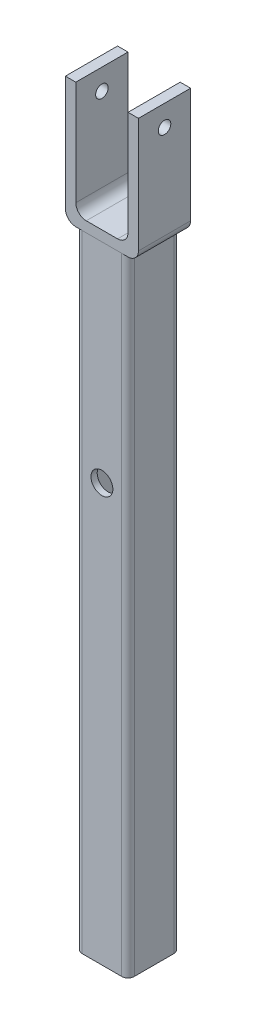
from build123d import *

# Parameters (mm, degrees)
BOSS_EXTRUDE1_DEPTH = 300
SKETCH2_R           = 7.5
CUT_EXTRUDE1_DEPTH  = 3
SKETCH3_R           = 5.25
CUT_EXTRUDE2_DEPTH  = 3
SKETCH5_W           = 35
SKETCH5_H           = 25
BOSS_EXTRUDE2_DEPTH = 60
SKETCH7_W           = 25
SKETCH7_H           = 25
CUT_EXTRUDE4_DEPTH  = 55
SKETCH8_R           = 3
CUT_EXTRUDE5_DEPTH  = 55
FILLET1_R           = 5
FILLET2_R           = 5


with BuildPart() as part:
    # Sketch1 → Boss-Extrude1 (new body)
    with BuildSketch(Plane(origin=(0, 0, 0), x_dir=(1, 0, 0), z_dir=(0, 1, 0))):
        with BuildLine():
            Line((9.5, 12.5), (-9.5, 12.5))
            ThreePointArc((-9.5, 12.5), (-11.621320344, 11.621320344), (-12.5, 9.5))
            Line((-12.5, 9.5), (-12.5, -9.5))
            ThreePointArc((-12.5, -9.5), (-11.621320344, -11.621320344), (-9.5, -12.5))
            Line((-9.5, -12.5), (9.5, -12.5))
            ThreePointArc((9.5, -12.5), (11.621320344, -11.621320344), (12.5, -9.5))
            Line((12.5, -9.5), (12.5, 9.5))
            ThreePointArc((12.5, 9.5), (11.621320344, 11.621320344), (9.5, 12.5))
        make_face()
        with BuildLine():
            Line((-6.5, 9.5), (6.5, 9.5))
            ThreePointArc((6.5, 9.5), (8.621320344, 8.621320344), (9.5, 6.5))
            Line((9.5, 6.5), (9.5, -6.5))
            ThreePointArc((9.5, -6.5), (8.621320344, -8.621320344), (6.5, -9.5))
            Line((6.5, -9.5), (-6.5, -9.5))
            ThreePointArc((-6.5, -9.5), (-8.621320344, -8.621320344), (-9.5, -6.5))
            Line((-9.5, -6.5), (-9.5, 6.5))
            ThreePointArc((-9.5, 6.5), (-8.621320344, 8.621320344), (-6.5, 9.5))
        make_face(mode=Mode.SUBTRACT)
    extrude(amount=BOSS_EXTRUDE1_DEPTH)

    # Sketch2 → Cut-Extrude1 (cut)
    with BuildSketch(Plane(origin=(0, 0, -12.5), x_dir=(-1, 0, 0), z_dir=(0, 0, -1))):
        with Locations((0, 200)):
            Circle(SKETCH2_R)
    extrude(amount=-CUT_EXTRUDE1_DEPTH, mode=Mode.SUBTRACT)

    # Sketch3 → Cut-Extrude2 (cut)
    with BuildSketch(Plane.XY.offset(12.5)):
        with Locations((0, 200)):
            Circle(SKETCH3_R)
    extrude(amount=-CUT_EXTRUDE2_DEPTH, mode=Mode.SUBTRACT)


with BuildPart() as body_2:
    # Sketch5 → Boss-Extrude2 (new body)
    with BuildSketch(Plane(origin=(0, 300, 0), x_dir=(1, 0, 0), z_dir=(0, 1, 0))):
        Rectangle(SKETCH5_W, SKETCH5_H)
    extrude(amount=BOSS_EXTRUDE2_DEPTH)

    # Sketch7 → Cut-Extrude4 (cut)
    with BuildSketch(Plane(origin=(0, 360, 0), x_dir=(1, 0, 0), z_dir=(0, 1, 0))):
        Rectangle(SKETCH7_W, SKETCH7_H)
    extrude(amount=-CUT_EXTRUDE4_DEPTH, mode=Mode.SUBTRACT)

    # Sketch8 → Cut-Extrude5 (cut)
    with BuildSketch(Plane.ZY.offset(17.5)):
        with Locations((0, 350)):
            Circle(SKETCH8_R)
    extrude(amount=-CUT_EXTRUDE5_DEPTH, mode=Mode.SUBTRACT)

    # Fillet1
    fillet1_edges = [body_2.edges().sort_by_distance(p)[0] for p in [
        (-12.5, 305, 0),
        (12.5, 305, 0),
    ]]
    fillet(fillet1_edges, radius=FILLET1_R)

    # Fillet2
    fillet2_edges = [body_2.edges().sort_by_distance(p)[0] for p in [
        (17.5, 300, 0),
        (-17.5, 300, 0),
    ]]
    fillet(fillet2_edges, radius=FILLET2_R)


solid = Compound([part.part, body_2.part])
